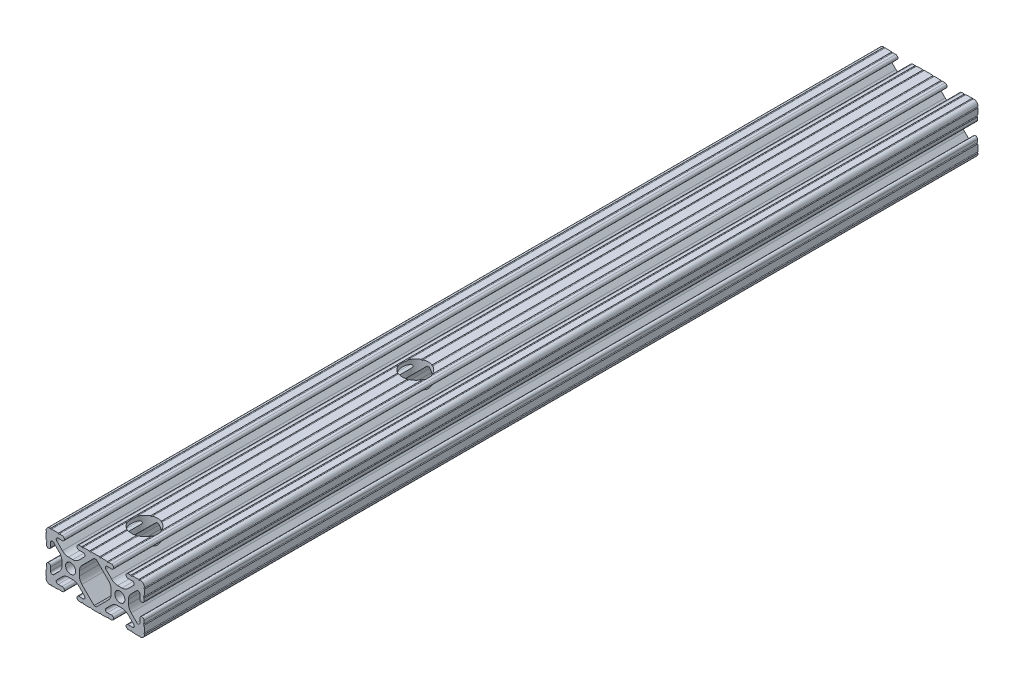
from build123d import *

# Parameters (mm, degrees)
SKETCH3_R          = 2.6035
EXTRUDE1_DEPTH     = 430
SKETCH4_R          = 6.75
CUT_EXTRUDE2_DEPTH = 26.39865385


with BuildPart() as part:
    # Sketch3 → Extrude1 (new body)
    with BuildSketch(Plane.XY):
        with BuildLine():
            Line((-1.115277175, 4.5085), (1.115277175, 4.5085))
            ThreePointArc((1.115277175, 4.5085), (2.806584872, 4.844922018), (4.240406305, 5.80297087))
            Line((4.240406305, 5.80297087), (7.148423664, 8.710988229))
            ThreePointArc((7.148423664, 8.710988229), (7.349906316, 9.772227925), (6.436353897, 10.348636575))
            Line((6.436353897, 10.348636575), (4.381960454, 10.276895575))
            ThreePointArc((4.381960454, 10.276895575), (3.239173075, 11.342562046), (4.304839546, 12.485349424))
            Line((4.304839546, 12.485349424), (5.728246175, 12.535055879))
            ThreePointArc((5.728246175, 12.535055879), (6.054756855, 12.230579745), (6.35923299, 12.557090424))
            Line((6.35923299, 12.557090424), (9.782092278, 12.676619304))
            ThreePointArc((9.782092278, 12.676619304), (10.108602958, 12.37214317), (10.413079092, 12.69865385))
            Line((10.413079092, 12.69865385), (14.986920908, 12.69865385))
            ThreePointArc((14.986920908, 12.69865385), (15.291397042, 12.37214317), (15.617907722, 12.676619304))
            Line((15.617907722, 12.676619304), (19.04076701, 12.557090424))
            ThreePointArc((19.04076701, 12.557090424), (19.345243145, 12.230579745), (19.671753825, 12.535055879))
            Line((19.671753825, 12.535055879), (21.095160454, 12.485349424))
            ThreePointArc((21.095160454, 12.485349424), (22.160826925, 11.342562046), (21.018039546, 10.276895575))
            Line((21.018039546, 10.276895575), (18.963646103, 10.348636575))
            ThreePointArc((18.963646103, 10.348636575), (18.050093684, 9.772227925), (18.251576336, 8.710988229))
            Line((18.251576336, 8.710988229), (21.159593695, 5.80297087))
            ThreePointArc((21.159593695, 5.80297087), (22.593415128, 4.844922018), (24.284722825, 4.5085))
            Line((24.284722825, 4.5085), (26.515277175, 4.5085))
            ThreePointArc((26.515277175, 4.5085), (28.206584872, 4.844922018), (29.640406305, 5.80297087))
            Line((29.640406305, 5.80297087), (32.548423664, 8.710988229))
            ThreePointArc((32.548423664, 8.710988229), (32.749906316, 9.772227925), (31.836353897, 10.348636575))
            Line((31.836353897, 10.348636575), (29.781960454, 10.276895575))
            ThreePointArc((29.781960454, 10.276895575), (28.639173075, 11.342562046), (29.704839546, 12.485349424))
            Line((29.704839546, 12.485349424), (31.128246175, 12.535055879))
            ThreePointArc((31.128246175, 12.535055879), (31.454756855, 12.230579745), (31.75923299, 12.557090424))
            Line((31.75923299, 12.557090424), (35.182092278, 12.676619304))
            ThreePointArc((35.182092278, 12.676619304), (35.508602958, 12.37214317), (35.813079092, 12.69865385))
            ThreePointArc((35.813079092, 12.69865385), (37.452764565, 12.052764565), (38.09865385, 10.413079092))
            ThreePointArc((38.09865385, 10.413079092), (37.77214317, 10.108602958), (38.076619304, 9.782092278))
            Line((38.076619304, 9.782092278), (37.957090424, 6.35923299))
            ThreePointArc((37.957090424, 6.35923299), (37.630579745, 6.054756855), (37.935055879, 5.728246175))
            Line((37.935055879, 5.728246175), (37.885349424, 4.304839546))
            ThreePointArc((37.885349424, 4.304839546), (36.742562046, 3.239173075), (35.676895575, 4.381960454))
            Line((35.676895575, 4.381960454), (35.748636575, 6.436353897))
            ThreePointArc((35.748636575, 6.436353897), (35.172227925, 7.349906316), (34.110988229, 7.148423664))
            Line((34.110988229, 7.148423664), (31.202971079, 4.240406514))
            ThreePointArc((31.202971079, 4.240406514), (30.244922075, 2.806585009), (29.9085, 1.115277175))
            Line((29.9085, 1.115277175), (29.9085, -1.115277175))
            ThreePointArc((29.9085, -1.115277175), (30.244922075, -2.806585009), (31.202971079, -4.240406514))
            Line((31.202971079, -4.240406514), (34.110988229, -7.148423664))
            ThreePointArc((34.110988229, -7.148423664), (35.172227925, -7.349906316), (35.748636575, -6.436353897))
            Line((35.748636575, -6.436353897), (35.676895575, -4.381960454))
            ThreePointArc((35.676895575, -4.381960454), (36.742562046, -3.239173075), (37.885349424, -4.304839546))
            Line((37.885349424, -4.304839546), (37.935055879, -5.728246175))
            ThreePointArc((37.935055879, -5.728246175), (37.630579745, -6.054756855), (37.957090424, -6.35923299))
            Line((37.957090424, -6.35923299), (38.076619304, -9.782092278))
            ThreePointArc((38.076619304, -9.782092278), (37.77214317, -10.108602958), (38.09865385, -10.413079092))
            ThreePointArc((38.09865385, -10.413079092), (37.452764565, -12.052764565), (35.813079092, -12.69865385))
            ThreePointArc((35.813079092, -12.69865385), (35.508602958, -12.37214317), (35.182092278, -12.676619304))
            Line((35.182092278, -12.676619304), (31.75923299, -12.557090424))
            ThreePointArc((31.75923299, -12.557090424), (31.454756855, -12.230579745), (31.128246175, -12.535055879))
            Line((31.128246175, -12.535055879), (29.704839546, -12.485349424))
            ThreePointArc((29.704839546, -12.485349424), (28.639173075, -11.342562046), (29.781960454, -10.276895575))
            Line((29.781960454, -10.276895575), (31.836353897, -10.348636575))
            ThreePointArc((31.836353897, -10.348636575), (32.749906316, -9.772227925), (32.548423664, -8.710988229))
            Line((32.548423664, -8.710988229), (29.640406305, -5.80297087))
            ThreePointArc((29.640406305, -5.80297087), (28.206584872, -4.844922018), (26.515277175, -4.5085))
            Line((26.515277175, -4.5085), (24.284722825, -4.5085))
            ThreePointArc((24.284722825, -4.5085), (22.593415128, -4.844922018), (21.159593695, -5.80297087))
            Line((21.159593695, -5.80297087), (18.251576336, -8.710988229))
            ThreePointArc((18.251576336, -8.710988229), (18.050093684, -9.772227925), (18.963646103, -10.348636575))
            Line((18.963646103, -10.348636575), (21.018039546, -10.276895575))
            ThreePointArc((21.018039546, -10.276895575), (22.160826925, -11.342562046), (21.095160454, -12.485349424))
            Line((21.095160454, -12.485349424), (19.671753825, -12.535055879))
            ThreePointArc((19.671753825, -12.535055879), (19.345243145, -12.230579745), (19.04076701, -12.557090424))
            Line((19.04076701, -12.557090424), (15.617907722, -12.676619304))
            ThreePointArc((15.617907722, -12.676619304), (15.291397042, -12.37214317), (14.986920908, -12.69865385))
            Line((14.986920908, -12.69865385), (10.413079092, -12.69865385))
            ThreePointArc((10.413079092, -12.69865385), (10.108602958, -12.37214317), (9.782092278, -12.676619304))
            Line((9.782092278, -12.676619304), (6.35923299, -12.557090424))
            ThreePointArc((6.35923299, -12.557090424), (6.054756855, -12.230579745), (5.728246175, -12.535055879))
            Line((5.728246175, -12.535055879), (4.304839546, -12.485349424))
            ThreePointArc((4.304839546, -12.485349424), (3.239173075, -11.342562046), (4.381960454, -10.276895575))
            Line((4.381960454, -10.276895575), (6.436353897, -10.348636575))
            ThreePointArc((6.436353897, -10.348636575), (7.349906316, -9.772227925), (7.148423664, -8.710988229))
            Line((7.148423664, -8.710988229), (4.240406305, -5.80297087))
            ThreePointArc((4.240406305, -5.80297087), (2.806584872, -4.844922018), (1.115277175, -4.5085))
            Line((1.115277175, -4.5085), (-1.115277175, -4.5085))
            ThreePointArc((-1.115277175, -4.5085), (-2.806584872, -4.844922018), (-4.240406305, -5.80297087))
            Line((-4.240406305, -5.80297087), (-7.148423664, -8.710988229))
            ThreePointArc((-7.148423664, -8.710988229), (-7.349906316, -9.772227925), (-6.436353897, -10.348636575))
            Line((-6.436353897, -10.348636575), (-4.381960454, -10.276895575))
            ThreePointArc((-4.381960454, -10.276895575), (-3.239173075, -11.342562046), (-4.304839546, -12.485349424))
            Line((-4.304839546, -12.485349424), (-5.728246175, -12.535055879))
            ThreePointArc((-5.728246175, -12.535055879), (-6.054756855, -12.230579745), (-6.35923299, -12.557090424))
            Line((-6.35923299, -12.557090424), (-9.782092278, -12.676619304))
            ThreePointArc((-9.782092278, -12.676619304), (-10.108602958, -12.37214317), (-10.413079092, -12.69865385))
            ThreePointArc((-10.413079092, -12.69865385), (-12.052764565, -12.052764565), (-12.69865385, -10.413079092))
            ThreePointArc((-12.69865385, -10.413079092), (-12.37214317, -10.108602958), (-12.676619304, -9.782092278))
            Line((-12.676619304, -9.782092278), (-12.557090424, -6.35923299))
            ThreePointArc((-12.557090424, -6.35923299), (-12.230579745, -6.054756855), (-12.535055879, -5.728246175))
            Line((-12.535055879, -5.728246175), (-12.485349424, -4.304839546))
            ThreePointArc((-12.485349424, -4.304839546), (-11.342562046, -3.239173075), (-10.276895575, -4.381960454))
            Line((-10.276895575, -4.381960454), (-10.348636575, -6.436353897))
            ThreePointArc((-10.348636575, -6.436353897), (-9.772227925, -7.349906316), (-8.710988229, -7.148423664))
            Line((-8.710988229, -7.148423664), (-5.802971079, -4.240406514))
            ThreePointArc((-5.802971079, -4.240406514), (-4.844922075, -2.806585009), (-4.5085, -1.115277175))
            Line((-4.5085, -1.115277175), (-4.5085, 1.115277175))
            ThreePointArc((-4.5085, 1.115277175), (-4.844922075, 2.806585009), (-5.802971079, 4.240406514))
            Line((-5.802971079, 4.240406514), (-8.710988229, 7.148423664))
            ThreePointArc((-8.710988229, 7.148423664), (-9.772227925, 7.349906316), (-10.348636575, 6.436353897))
            Line((-10.348636575, 6.436353897), (-10.276895575, 4.381960454))
            ThreePointArc((-10.276895575, 4.381960454), (-11.342562046, 3.239173075), (-12.485349424, 4.304839546))
            Line((-12.485349424, 4.304839546), (-12.535055879, 5.728246175))
            ThreePointArc((-12.535055879, 5.728246175), (-12.230579745, 6.054756855), (-12.557090424, 6.35923299))
            Line((-12.557090424, 6.35923299), (-12.676619304, 9.782092278))
            ThreePointArc((-12.676619304, 9.782092278), (-12.37214317, 10.108602958), (-12.69865385, 10.413079092))
            ThreePointArc((-12.69865385, 10.413079092), (-12.052764565, 12.052764565), (-10.413079092, 12.69865385))
            ThreePointArc((-10.413079092, 12.69865385), (-10.108602958, 12.37214317), (-9.782092278, 12.676619304))
            Line((-9.782092278, 12.676619304), (-6.35923299, 12.557090424))
            ThreePointArc((-6.35923299, 12.557090424), (-6.054756855, 12.230579745), (-5.728246175, 12.535055879))
            Line((-5.728246175, 12.535055879), (-4.304839546, 12.485349424))
            ThreePointArc((-4.304839546, 12.485349424), (-3.239173075, 11.342562046), (-4.381960454, 10.276895575))
            Line((-4.381960454, 10.276895575), (-6.436353897, 10.348636575))
            ThreePointArc((-6.436353897, 10.348636575), (-7.349906316, 9.772227925), (-7.148423664, 8.710988229))
            Line((-7.148423664, 8.710988229), (-4.240406305, 5.80297087))
            ThreePointArc((-4.240406305, 5.80297087), (-2.806584872, 4.844922018), (-1.115277175, 4.5085))
        make_face()
        with Locations((25.4, 0)):
            Circle(SKETCH3_R, mode=Mode.SUBTRACT)
        Circle(SKETCH3_R, mode=Mode.SUBTRACT)
        with BuildLine():
            Line((5.802971079, 4.240406514), (12.109304956, 10.546740391))
            Line((12.109304956, 10.546740391), (12.7, 10.567367916))
            Line((12.7, 10.567367916), (13.290695044, 10.546740391))
            Line((13.290695044, 10.546740391), (19.597028921, 4.240406514))
            ThreePointArc((19.597028921, 4.240406514), (20.555077925, 2.806585009), (20.8915, 1.115277175))
            Line((20.8915, 1.115277175), (20.8915, -1.115277175))
            ThreePointArc((20.8915, -1.115277175), (20.555077925, -2.806585009), (19.597028921, -4.240406514))
            Line((19.597028921, -4.240406514), (13.290695044, -10.546740391))
            Line((13.290695044, -10.546740391), (12.7, -10.567367916))
            Line((12.7, -10.567367916), (12.109304956, -10.546740391))
            Line((12.109304956, -10.546740391), (5.802971079, -4.240406514))
            ThreePointArc((5.802971079, -4.240406514), (4.844922075, -2.806585009), (4.5085, -1.115277175))
            Line((4.5085, -1.115277175), (4.5085, 1.115277175))
            ThreePointArc((4.5085, 1.115277175), (4.844922075, 2.806585009), (5.802971079, 4.240406514))
        make_face(mode=Mode.SUBTRACT)
    extrude(amount=EXTRUDE1_DEPTH)

    # Sketch4 → Cut-Extrude2 (cut, through all)
    with BuildSketch(Plane(origin=(0, 12.69865385, 0), x_dir=(1, 0, 0), z_dir=(0, 1, 0))):
        with Locations((12.7, -404.6)):
            Circle(SKETCH4_R)
        with Locations((12.7, -264.9)):
            Circle(SKETCH4_R)
    extrude(amount=-CUT_EXTRUDE2_DEPTH, mode=Mode.SUBTRACT)


solid = part.part
